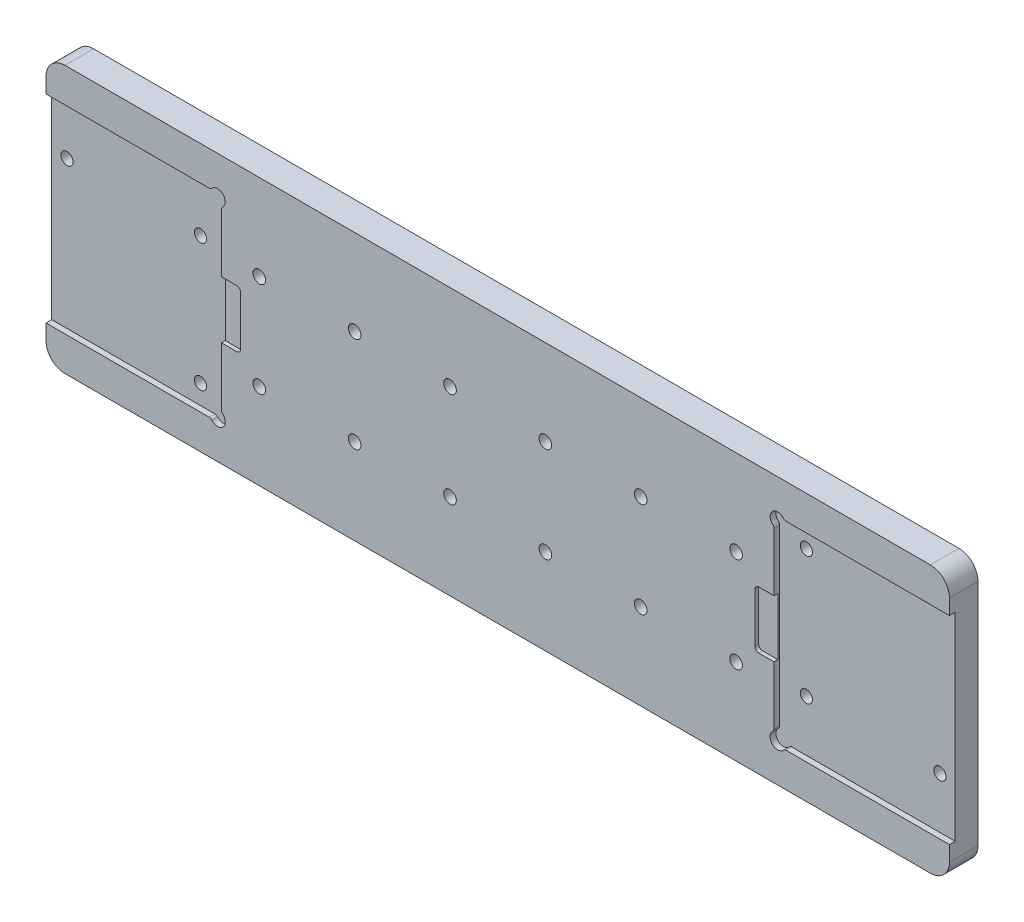
from build123d import *

# Parameters (mm, degrees)
ESTRUSIONE_ESTRUSIONE1_DEPTH                         = 3
ESTRUSIONE_ESTRUSIONE1_DEPTH_BACK                    = 12
TAGLIO_ESTRUSIONE1_DEPTH                             = 3
FORO_LAMATO_PER_VITE_M6_A_TESTA_CILINDRI_D           = 6.4
FORO_LAMATO_PER_VITE_M6_A_TESTA_CILINDRI_CBORE_D     = 11
FORO_LAMATO_PER_VITE_M6_A_TESTA_CILINDRI_CBORE_DEPTH = 6.4
FORO_PER_VITE_M6_1_D                                 = 6.6
TAGLIO_ESTRUSIONE2_DEPTH                             = 2
RIPETIZIONECIRCOLARE1_COUNT                          = 2


with BuildPart() as part:
    # Schizzo1 → Estrusione-Estrusione1 (new body, two sides)
    with BuildSketch(Plane.XY) as estrusione_estrusione1_sk:
        with BuildLine():
            Line((-181.4, 70), (272.3, 70))
            ThreePointArc((272.3, 70), (279.371067812, 67.071067812), (282.3, 60))
            Line((282.3, 60), (282.3, -60))
            ThreePointArc((282.3, -60), (279.371067812, -67.071067812), (272.3, -70))
            Line((272.3, -70), (-181.4, -70))
            ThreePointArc((-181.4, -70), (-188.471067812, -67.071067812), (-191.4, -60))
            Line((-191.4, -60), (-191.4, 60))
            ThreePointArc((-191.4, 60), (-188.471067812, 67.071067812), (-181.4, 70))
        make_face()
    extrude(amount=ESTRUSIONE_ESTRUSIONE1_DEPTH)
    extrude(estrusione_estrusione1_sk.sketch, amount=-ESTRUSIONE_ESTRUSIONE1_DEPTH_BACK)

    # Schizzo2 → Taglio-Estrusione1 (cut)
    with BuildSketch(Plane.XY.offset(3)):
        with BuildLine():
            Line((196.772135955, 52), (282.3, 52))
            Line((282.3, 52), (282.3, -52))
            Line((282.3, -52), (196.772135955, -52))
            ThreePointArc((196.772135955, -52), (195.955639374, -52.174258142), (195.28142397, -52.666666667))
            ThreePointArc((195.28142397, -52.666666667), (189.471572875, -52.828427125), (189.633333333, -47.01857603))
            ThreePointArc((189.633333333, -47.01857603), (190.125741858, -46.344360626), (190.3, -45.527864045))
            Line((190.3, -45.527864045), (190.3, 45.527864045))
            ThreePointArc((190.3, 45.527864045), (190.125741858, 46.344360626), (189.633333333, 47.01857603))
            ThreePointArc((189.633333333, 47.01857603), (189.471572875, 52.828427125), (195.28142397, 52.666666667))
            ThreePointArc((195.28142397, 52.666666667), (195.955639374, 52.174258142), (196.772135955, 52))
        make_face()
    taglio_estrusione1 = extrude(amount=-TAGLIO_ESTRUSIONE1_DEPTH, mode=Mode.SUBTRACT)

    # Foro lamato per Vite M6 a testa cilindri (through all)
    with Locations(Plane(origin=(0, 0, -12), x_dir=(-1, 0, 0), z_dir=(0, 0, -1))):
        with Locations((-204.3, 41.814954576), (-204.3, -25.185045424), (-274.3, -25.185045424)):
            foro_lamato_per_vite_m6_a_testa_cilindri = CounterBoreHole(FORO_LAMATO_PER_VITE_M6_A_TESTA_CILINDRI_D / 2, FORO_LAMATO_PER_VITE_M6_A_TESTA_CILINDRI_CBORE_D / 2, FORO_LAMATO_PER_VITE_M6_A_TESTA_CILINDRI_CBORE_DEPTH)

    # Foro per Vite M6-1 (through all)
    with Locations(Plane.XY.offset(3)):
        with Locations((170.45, -25), (-79.55, 25), (170.45, 25), (-79.55, -25), (120.45, -25), (120.45, 25), (70.45, 25), (70.45, -25), (20.45, 25), (20.45, -25), (-29.55, -25), (-29.55, 25)):
            Hole(FORO_PER_VITE_M6_1_D / 2)

    # Schizzo7 → Taglio-Estrusione2 (cut)
    with BuildSketch(Plane.XY.offset(3)):
        with BuildLine():
            Line((182.3, 15), (200.3, 15))
            Line((200.3, 15), (200.3, -15))
            Line((200.3, -15), (182.3, -15))
            ThreePointArc((182.3, -15), (180.885786438, -14.414213562), (180.3, -13))
            Line((180.3, -13), (180.3, 13))
            ThreePointArc((180.3, 13), (180.885786438, 14.414213562), (182.3, 15))
        make_face()
    taglio_estrusione2 = extrude(amount=-TAGLIO_ESTRUSIONE2_DEPTH, mode=Mode.SUBTRACT)

    # RipetizioneCircolare1: Taglio-Estrusione1, Foro lamato per Vite M6 a testa cilindri, Taglio-Estrusione2 ×2 about axis
    ripetizionecircolare1_axis = Axis((45.45, 0, 0), (0, 0, 1))
    add([taglio_estrusione1.rotate(ripetizionecircolare1_axis, i * 360 / RIPETIZIONECIRCOLARE1_COUNT) for i in range(1, RIPETIZIONECIRCOLARE1_COUNT)], mode=Mode.SUBTRACT)
    add([foro_lamato_per_vite_m6_a_testa_cilindri.rotate(ripetizionecircolare1_axis, i * 360 / RIPETIZIONECIRCOLARE1_COUNT) for i in range(1, RIPETIZIONECIRCOLARE1_COUNT)], mode=Mode.SUBTRACT)
    add([taglio_estrusione2.rotate(ripetizionecircolare1_axis, i * 360 / RIPETIZIONECIRCOLARE1_COUNT) for i in range(1, RIPETIZIONECIRCOLARE1_COUNT)], mode=Mode.SUBTRACT)


solid = part.part
